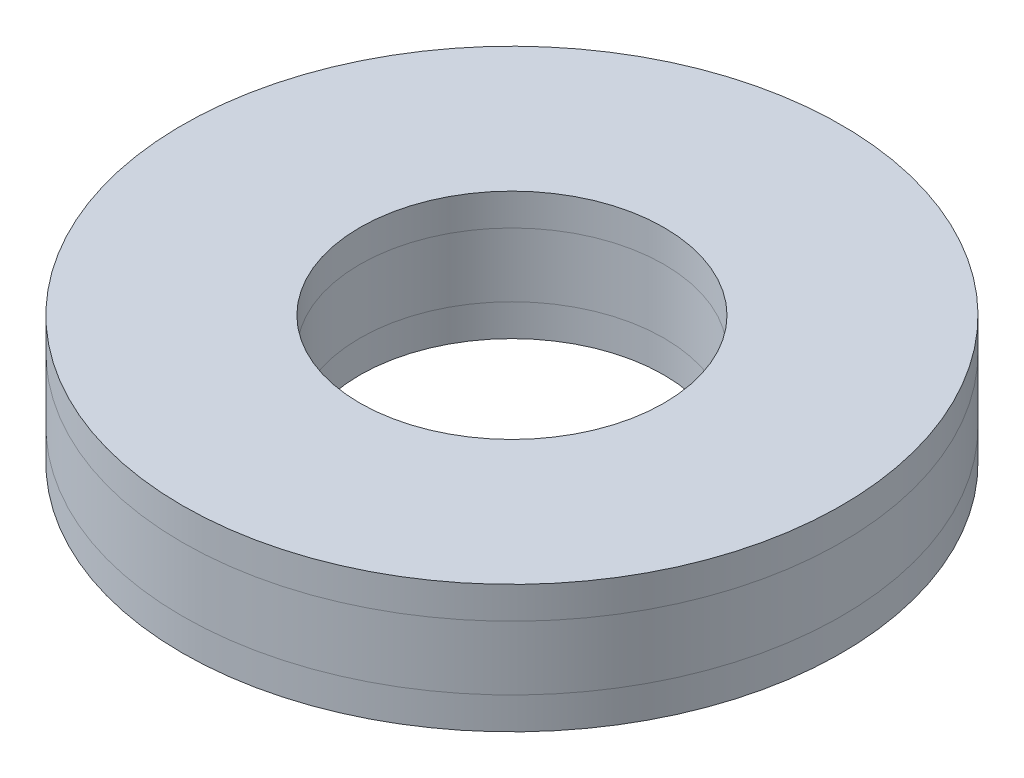
from build123d import *

# Parameters (mm, degrees)
SKETCH1_R           = 10.32
SKETCH1_R_2         = 4.7625
BOSS_EXTRUDE1_DEPTH = 1
SKETCH2_R           = 10.32
SKETCH2_R_2         = 4.7625
BOSS_EXTRUDE2_DEPTH = 2
SKETCH3_R           = 10.32
SKETCH3_R_2         = 4.7625
BOSS_EXTRUDE3_DEPTH = 1


with BuildPart() as part:
    # Sketch1 → Boss-Extrude1 (new body)
    with BuildSketch(Plane(origin=(0, 0, 0), x_dir=(1, 0, 0), z_dir=(0, 1, 0))):
        Circle(SKETCH1_R)
        Circle(SKETCH1_R_2, mode=Mode.SUBTRACT)
    extrude(amount=BOSS_EXTRUDE1_DEPTH)


with BuildPart() as body_2:
    # Sketch2 → Boss-Extrude2 (new body)
    with BuildSketch(Plane(origin=(0, 1, 0), x_dir=(1, 0, 0), z_dir=(0, 1, 0))):
        Circle(SKETCH2_R)
        Circle(SKETCH2_R_2, mode=Mode.SUBTRACT)
    extrude(amount=BOSS_EXTRUDE2_DEPTH)


with BuildPart() as body_3:
    # Sketch3 → Boss-Extrude3 (new body)
    with BuildSketch(Plane(origin=(0, 3, 0), x_dir=(1, 0, 0), z_dir=(0, 1, 0))):
        Circle(SKETCH3_R)
        Circle(SKETCH3_R_2, mode=Mode.SUBTRACT)
    extrude(amount=BOSS_EXTRUDE3_DEPTH)


solid = Compound([part.part, body_2.part, body_3.part])
